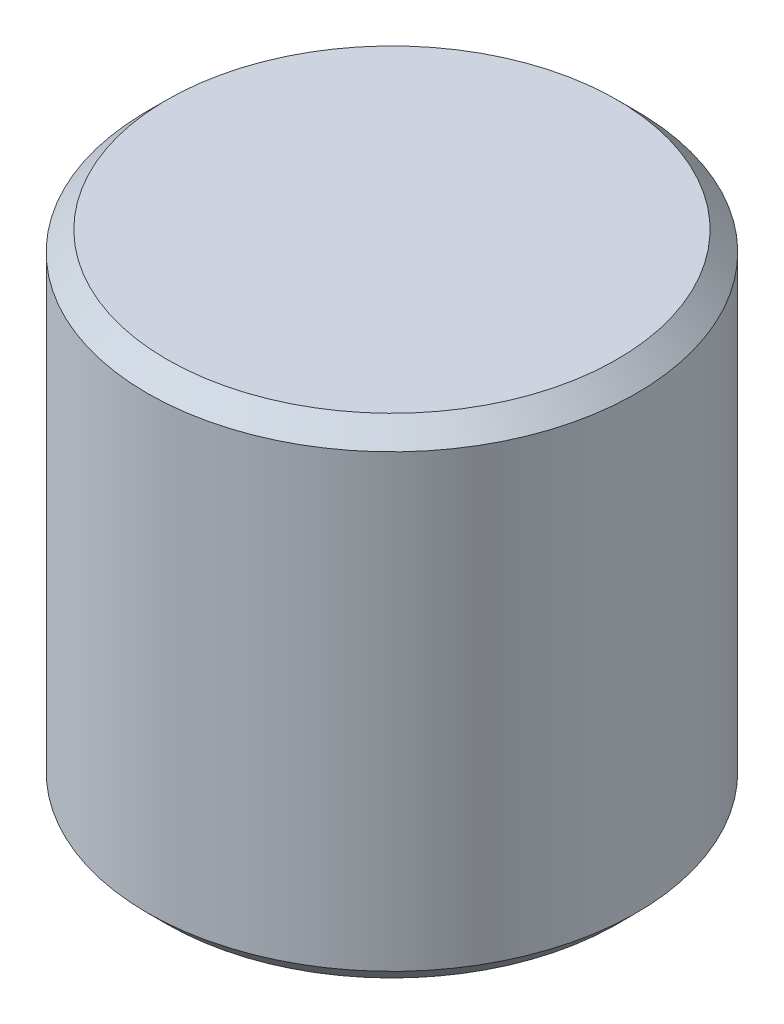
from build123d import *

# Parameters (mm, degrees)
SKETCH1_R           = 5
BOSS_EXTRUDE1_DEPTH = 10
CHAMFER1_SIZE       = 0.4


with BuildPart() as part:
    # Sketch1 → Boss-Extrude1 (new body)
    with BuildSketch(Plane(origin=(0, 0, 0), x_dir=(1, 0, 0), z_dir=(0, 1, 0))):
        Circle(SKETCH1_R)
    extrude(amount=BOSS_EXTRUDE1_DEPTH)

    # Chamfer1
    chamfer1_edges = [part.edges().sort_by_distance(p)[0] for p in [
        (-5, 0, 0),
        (-5, 10, 0),
    ]]
    chamfer(chamfer1_edges, length=CHAMFER1_SIZE)


solid = part.part
